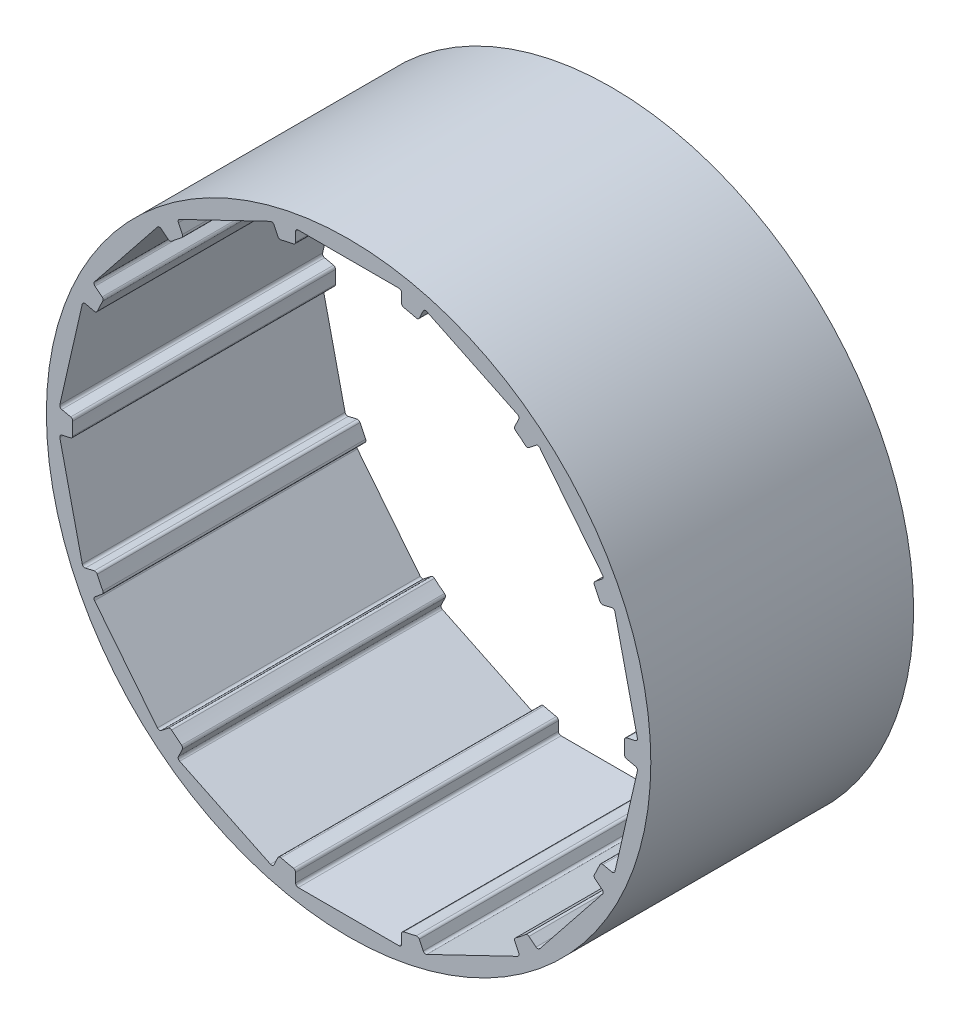
from build123d import *

# Parameters (mm, degrees)
SKETCH_5_R               = 34.5
SKETCH_5_R_2             = 31.5
EXTRUDE_3_DEPTH          = 30
SKETCH_6_W               = 12.1
SKETCH_6_H               = 2
CUT_EXTRUDE_1_DEPTH      = 58.275649276
PATTERN_CIRCULAR_4_COUNT = 14
FILLET_1_R               = 0.3
FILLET_2_R               = 0.3
FILLET_3_R               = 0.3


with BuildPart() as part:
    # ｽｹｯﾁ5 → ﾎﾞｽ - 押し出し3 (new body)
    with BuildSketch(Plane.XY):
        Circle(SKETCH_5_R)
        Circle(SKETCH_5_R_2, mode=Mode.SUBTRACT)
    extrude(amount=EXTRUDE_3_DEPTH)

    # ｽｹｯﾁ6 → ｶｯﾄ - 押し出し1 (cut, through all)
    with BuildSketch(Plane.XY.offset(30)):
        with Locations((0, 31.5)):
            Rectangle(SKETCH_6_W, SKETCH_6_H)
    cut_extrude_1 = extrude(amount=-CUT_EXTRUDE_1_DEPTH, mode=Mode.SUBTRACT)

    # 円形ﾊﾟﾀｰﾝ4: ｶｯﾄ - 押し出し1 ×14 about axis
    pattern_circular_4_axis = Axis((0, 0, 0), (0, 0, 1))
    for i in range(1, PATTERN_CIRCULAR_4_COUNT):
        add(cut_extrude_1.rotate(pattern_circular_4_axis, i * 360 / PATTERN_CIRCULAR_4_COUNT), mode=Mode.SUBTRACT)

    # ﾌｨﾚｯﾄ1
    fillet_1_edges = [part.edges().sort_by_distance(p)[0] for p in [
        (-6.05, 32.5, 15),
        (-8.650359871, 31.906484828, 15),
        (-6.05, 30.91354881, 15),
        (-7.962024496, 30.477141695, 15),
    ]]
    fillet(fillet_1_edges, radius=FILLET_1_R)

    # ﾌｨﾚｯﾄ2
    fillet_2_edges = [part.edges().sort_by_distance(p)[0] for p in [
        (19.552083172, -26.656491585, 15),
        (18.863747798, -25.227148452, 15),
        (20.397072393, -24.004362891, 15),
        (21.637409879, -24.993499029, 15),
        (30.338905495, -13.130244222, 15),
        (29.181636481, -15.533338091, 15),
        (27.941298995, -14.544201953, 15),
        (28.792229949, -12.777225622, 15),
        (33.031408796, 1.333616485, 15),
        (31.484733249, 0.980597884, 15),
        (33.031408796, -1.333616485, 15),
        (31.484733249, -0.980597884, 15),
        (30.338905495, 13.130244222, 15),
        (28.792229949, 12.777225622, 15),
        (27.941298995, 14.544201953, 15),
        (29.181636481, 15.533338091, 15),
        (19.552083172, 26.656491585, 15),
        (21.637409879, 24.993499029, 15),
        (20.397072393, 24.004362891, 15),
        (18.863747798, 25.227148452, 15),
        (6.05, 32.5, 15),
        (8.650359871, 31.906484828, 15),
        (7.962024496, 30.477141695, 15),
        (6.05, 30.91354881, 15),
    ]]
    fillet(fillet_2_edges, radius=FILLET_2_R)

    # ﾌｨﾚｯﾄ3
    fillet_3_edges = [part.edges().sort_by_distance(p)[0] for p in [
        (-21.637409879, 24.993499029, 15),
        (-19.552083172, 26.656491585, 15),
        (-18.863747798, 25.227148452, 15),
        (-20.397072393, 24.004362891, 15),
        (-27.941298995, 14.544201953, 15),
        (-29.181636481, 15.533338091, 15),
        (-30.338905495, 13.130244222, 15),
        (-28.792229949, 12.777225622, 15),
        (-33.031408796, 1.333616485, 15),
        (-31.484733249, 0.980597884, 15),
        (-31.484733249, -0.980597884, 15),
        (-33.031408796, -1.333616485, 15),
        (-29.181636481, -15.533338091, 15),
        (-30.338905495, -13.130244222, 15),
        (-28.792229949, -12.777225622, 15),
        (-27.941298995, -14.544201953, 15),
        (-19.552083172, -26.656491585, 15),
        (-21.637409879, -24.993499029, 15),
        (-18.863747798, -25.227148452, 15),
        (-20.397072393, -24.004362891, 15),
        (-8.650359871, -31.906484828, 15),
        (-6.05, -30.91354881, 15),
        (-6.05, -32.5, 15),
        (-7.962024496, -30.477141695, 15),
        (6.05, -32.5, 15),
        (6.05, -30.91354881, 15),
        (7.962024496, -30.477141695, 15),
        (8.650359871, -31.906484828, 15),
    ]]
    fillet(fillet_3_edges, radius=FILLET_3_R)


solid = part.part
